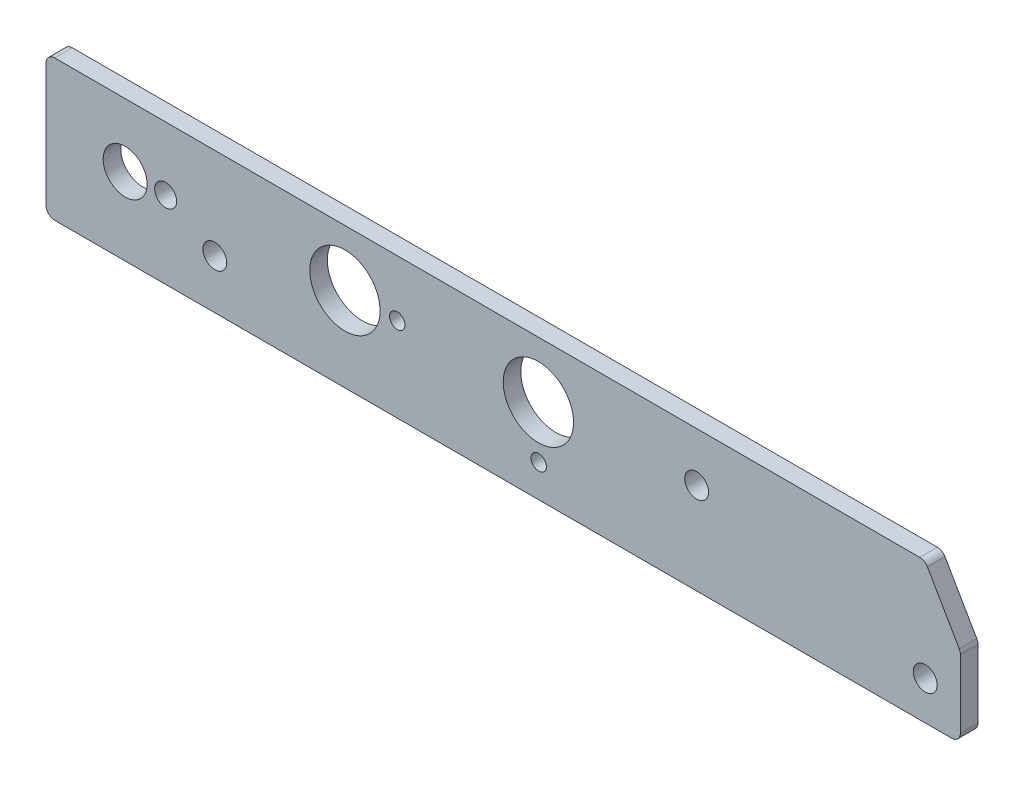
from build123d import *

# Parameters (mm, degrees)
BOSS_EXTRUDE1_DEPTH             = 3.175
F_1_2_0_5_DIAMETER_HOLE1_D      = 12.7
F_5_16_0_3125_DIAMETER_HOLE1_D  = 7.9375
F_5_32_0_15625_DIAMETER_HOLE1_D = 3.96875
F_7_64_0_10938_DIAMETER_HOLE1_D = 2.778252
F_6_CLEARANCE_HOLE1_D           = 4.3053


with BuildPart() as part:
    # Sketch1 → Boss-Extrude1 (new body)
    with BuildSketch(Plane.XY):
        with BuildLine():
            Line((157.767651581, 0), (1.5875, 0))
            ThreePointArc((1.5875, 0), (0.464967985, -0.464967985), (0, -1.5875))
            Line((0, -1.5875), (0, -23.8125))
            ThreePointArc((0, -23.8125), (0.464967985, -24.935032015), (1.5875, -25.4))
            Line((1.5875, -25.4), (163.5125, -25.4))
            ThreePointArc((163.5125, -25.4), (164.635032015, -24.935032015), (165.1, -23.8125))
            Line((165.1, -23.8125), (165.1, -11.537869343))
            ThreePointArc((165.1, -11.537869343), (165.045907249, -11.126994109), (164.887315329, -10.744119343))
            Line((164.887315329, -10.744119343), (159.14246691, -0.79375))
            ThreePointArc((159.14246691, -0.79375), (158.561401581, -0.212684671), (157.767651581, 0))
        make_face()
    extrude(amount=BOSS_EXTRUDE1_DEPTH)

    # 1/2 (0.5) Diameter Hole1 (through all)
    with Locations(Plane(origin=(0, 0, 0), x_dir=(-1, 0, 0), z_dir=(0, 0, -1))):
        with Locations((-53.975, -10.16), (-88.9, -10.16)):
            Hole(F_1_2_0_5_DIAMETER_HOLE1_D / 2)

    # 5/16 (0.3125) Diameter Hole1 (through all)
    with Locations(Plane(origin=(0, 0, 0), x_dir=(-1, 0, 0), z_dir=(0, 0, -1))):
        with Locations((-14.2875, -11.43)):
            Hole(F_5_16_0_3125_DIAMETER_HOLE1_D / 2)

    # 5/32 (0.15625) Diameter Hole1 (through all)
    with Locations(Plane(origin=(0, 0, 0), x_dir=(-1, 0, 0), z_dir=(0, 0, -1))):
        with Locations((-21.598282462, -11.43)):
            Hole(F_5_32_0_15625_DIAMETER_HOLE1_D / 2)

    # 7/64 (0.10938) Diameter Hole1 (through all)
    with Locations(Plane(origin=(0, 0, 0), x_dir=(-1, 0, 0), z_dir=(0, 0, -1))):
        with Locations((-88.959471598, -19.537541197), (-63.423407807, -10.16)):
            Hole(F_7_64_0_10938_DIAMETER_HOLE1_D / 2)

    # #6 Clearance Hole1 (through all)
    with Locations(Plane(origin=(0, 0, 0), x_dir=(-1, 0, 0), z_dir=(0, 0, -1))):
        with Locations((-158.75, -18.415), (-117.475, -8.89), (-30.48, -16.51)):
            Hole(F_6_CLEARANCE_HOLE1_D / 2)


solid = part.part
